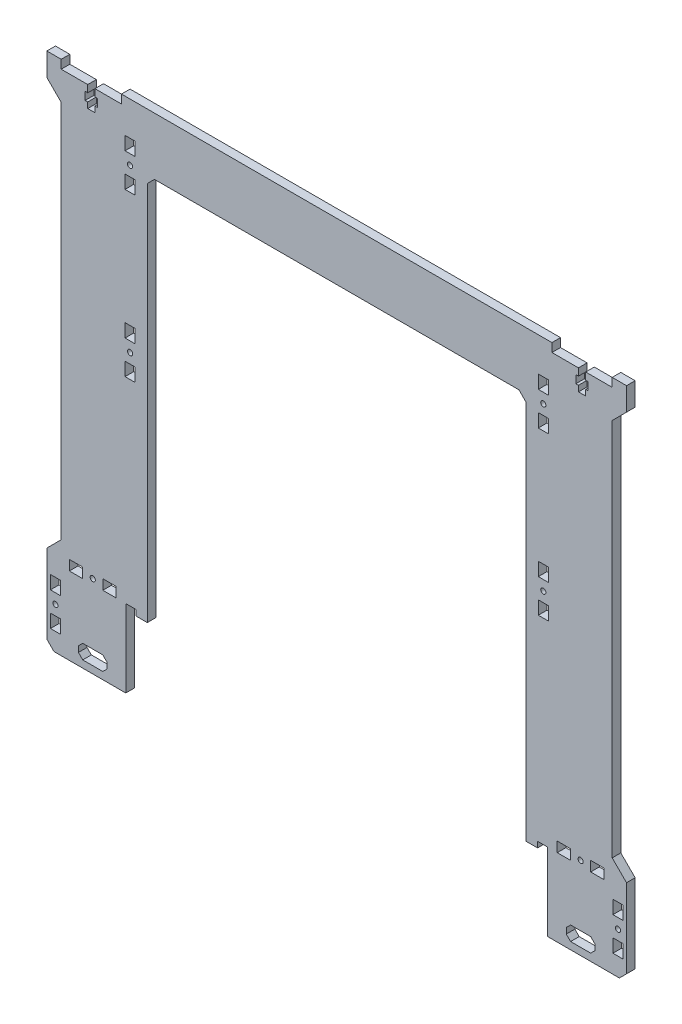
from build123d import *

# Parameters (mm, degrees)
BOSS_EXTRU_1_DEPTH      = 3
ENL_V_MAT_EXTRU_1_REACH = 8
ESQUISSE2_W             = 7
ESQUISSE2_H             = 9.3
ESQUISSE2_R             = 1.8
ESQUISSE2_W_2           = 9.3
ESQUISSE2_H_2           = 7
CHANFREIN1_SIZE         = 5


with BuildPart() as part:
    # Esquisse1 → Boss.-Extru.1 (new body, symmetric)
    with BuildSketch(Plane.XY):
        Polygon((0, 0), (0, 40), (-150, 40), (-150, 34), (-192, 34), (-192, 40), (-202, 40), (-202, 24), (-192, 14), (-192, -250), (-202, -260), (-202, -320), (-147, -320), (-147, -266), (-140, -266), (-140, -270), (-132, -270), (-132, 0), align=None)
    extrude(amount=BOSS_EXTRU_1_DEPTH, both=True)

    # Esquisse2 → Enlèv. mat.-Extru.1 (cut, up to next)
    with BuildSketch(Plane.XY.offset(3), mode=Mode.PRIVATE) as enl_v_mat_extru_1_sk1:
        with Locations((-144, 11.65)):
            Rectangle(ESQUISSE2_W, ESQUISSE2_H)
    enl_v_mat_extru_1_tool1 = extrude(enl_v_mat_extru_1_sk1.sketch, amount=-ENL_V_MAT_EXTRU_1_REACH, mode=Mode.PRIVATE) & part.part
    add(enl_v_mat_extru_1_tool1.solids().sort_by_distance((-144, 11.65, 3))[0], mode=Mode.SUBTRACT)
    # Esquisse2 → Enlèv. mat.-Extru.1 (cut, up to next)
    with BuildSketch(Plane.XY.offset(3), mode=Mode.PRIVATE) as enl_v_mat_extru_1_sk2:
        with Locations((-144, -11.65)):
            Rectangle(ESQUISSE2_W, ESQUISSE2_H)
    enl_v_mat_extru_1_tool2 = extrude(enl_v_mat_extru_1_sk2.sketch, amount=-ENL_V_MAT_EXTRU_1_REACH, mode=Mode.PRIVATE) & part.part
    add(enl_v_mat_extru_1_tool2.solids().sort_by_distance((-144, -11.65, 3))[0], mode=Mode.SUBTRACT)
    # Esquisse2 → Enlèv. mat.-Extru.1 (cut, up to next)
    with BuildSketch(Plane.XY.offset(3), mode=Mode.PRIVATE) as enl_v_mat_extru_1_sk3:
        with Locations((-144, -101.35)):
            Rectangle(ESQUISSE2_W, ESQUISSE2_H)
    enl_v_mat_extru_1_tool3 = extrude(enl_v_mat_extru_1_sk3.sketch, amount=-ENL_V_MAT_EXTRU_1_REACH, mode=Mode.PRIVATE) & part.part
    add(enl_v_mat_extru_1_tool3.solids().sort_by_distance((-144, -101.35, 3))[0], mode=Mode.SUBTRACT)
    # Esquisse2 → Enlèv. mat.-Extru.1 (cut, up to next)
    with BuildSketch(Plane.XY.offset(3), mode=Mode.PRIVATE) as enl_v_mat_extru_1_sk4:
        with Locations((-144, -113)):
            Circle(ESQUISSE2_R)
    enl_v_mat_extru_1_tool4 = extrude(enl_v_mat_extru_1_sk4.sketch, amount=-ENL_V_MAT_EXTRU_1_REACH, mode=Mode.PRIVATE) & part.part
    add(enl_v_mat_extru_1_tool4.solids().sort_by_distance((-144, -113, 3))[0], mode=Mode.SUBTRACT)
    # Esquisse2 → Enlèv. mat.-Extru.1 (cut, up to next)
    with BuildSketch(Plane.XY.offset(3), mode=Mode.PRIVATE) as enl_v_mat_extru_1_sk5:
        with Locations((-144, 0)):
            Circle(ESQUISSE2_R)
    enl_v_mat_extru_1_tool5 = extrude(enl_v_mat_extru_1_sk5.sketch, amount=-ENL_V_MAT_EXTRU_1_REACH, mode=Mode.PRIVATE) & part.part
    add(enl_v_mat_extru_1_tool5.solids().sort_by_distance((-144, 0, 3))[0], mode=Mode.SUBTRACT)
    # Esquisse2 → Enlèv. mat.-Extru.1 (cut, up to next)
    with BuildSketch(Plane.XY.offset(3), mode=Mode.PRIVATE) as enl_v_mat_extru_1_sk6:
        Polygon((-168.5, 34), (-173.5, 34), (-173.5, 29), (-175.3, 29), (-175.3, 23.5), (-173.5, 23.5), (-173.5, 19.5), (-168.5, 19.5), (-168.5, 23.5), (-166.7, 23.5), (-166.7, 29), (-168.5, 29), align=None)
    enl_v_mat_extru_1_tool6 = extrude(enl_v_mat_extru_1_sk6.sketch, amount=-ENL_V_MAT_EXTRU_1_REACH, mode=Mode.PRIVATE) & part.part
    add(enl_v_mat_extru_1_tool6.solids().sort_by_distance((-171, 26.642741, 3))[0], mode=Mode.SUBTRACT)
    # Esquisse2 → Enlèv. mat.-Extru.1 (cut, up to next)
    with BuildSketch(Plane.XY.offset(3), mode=Mode.PRIVATE) as enl_v_mat_extru_1_sk7:
        with Locations((-144, -124.65)):
            Rectangle(ESQUISSE2_W, ESQUISSE2_H)
    enl_v_mat_extru_1_tool7 = extrude(enl_v_mat_extru_1_sk7.sketch, amount=-ENL_V_MAT_EXTRU_1_REACH, mode=Mode.PRIVATE) & part.part
    add(enl_v_mat_extru_1_tool7.solids().sort_by_distance((-144, -124.65, 3))[0], mode=Mode.SUBTRACT)
    # Esquisse2 → Enlèv. mat.-Extru.1 (cut, up to next)
    with BuildSketch(Plane.XY.offset(3), mode=Mode.PRIVATE) as enl_v_mat_extru_1_sk8:
        with Locations((-158.35, -262.5)):
            Rectangle(ESQUISSE2_W_2, ESQUISSE2_H_2)
    enl_v_mat_extru_1_tool8 = extrude(enl_v_mat_extru_1_sk8.sketch, amount=-ENL_V_MAT_EXTRU_1_REACH, mode=Mode.PRIVATE) & part.part
    add(enl_v_mat_extru_1_tool8.solids().sort_by_distance((-158.35, -262.5, 3))[0], mode=Mode.SUBTRACT)
    # Esquisse2 → Enlèv. mat.-Extru.1 (cut, up to next)
    with BuildSketch(Plane.XY.offset(3), mode=Mode.PRIVATE) as enl_v_mat_extru_1_sk9:
        with Locations((-170, -262.5)):
            Circle(ESQUISSE2_R)
    enl_v_mat_extru_1_tool9 = extrude(enl_v_mat_extru_1_sk9.sketch, amount=-ENL_V_MAT_EXTRU_1_REACH, mode=Mode.PRIVATE) & part.part
    add(enl_v_mat_extru_1_tool9.solids().sort_by_distance((-170, -262.5, 3))[0], mode=Mode.SUBTRACT)
    # Esquisse2 → Enlèv. mat.-Extru.1 (cut, up to next)
    with BuildSketch(Plane.XY.offset(3), mode=Mode.PRIVATE) as enl_v_mat_extru_1_sk10:
        with Locations((-181.65, -262.5)):
            Rectangle(ESQUISSE2_W_2, ESQUISSE2_H_2)
    enl_v_mat_extru_1_tool10 = extrude(enl_v_mat_extru_1_sk10.sketch, amount=-ENL_V_MAT_EXTRU_1_REACH, mode=Mode.PRIVATE) & part.part
    add(enl_v_mat_extru_1_tool10.solids().sort_by_distance((-181.65, -262.5, 3))[0], mode=Mode.SUBTRACT)
    # Esquisse2 → Enlèv. mat.-Extru.1 (cut, up to next)
    with BuildSketch(Plane.XY.offset(3), mode=Mode.PRIVATE) as enl_v_mat_extru_1_sk11:
        with Locations((-196, -279.35)):
            Rectangle(ESQUISSE2_W, ESQUISSE2_H)
    enl_v_mat_extru_1_tool11 = extrude(enl_v_mat_extru_1_sk11.sketch, amount=-ENL_V_MAT_EXTRU_1_REACH, mode=Mode.PRIVATE) & part.part
    add(enl_v_mat_extru_1_tool11.solids().sort_by_distance((-196, -279.35, 3))[0], mode=Mode.SUBTRACT)
    # Esquisse2 → Enlèv. mat.-Extru.1 (cut, up to next)
    with BuildSketch(Plane.XY.offset(3), mode=Mode.PRIVATE) as enl_v_mat_extru_1_sk12:
        with Locations((-196, -291)):
            Circle(ESQUISSE2_R)
    enl_v_mat_extru_1_tool12 = extrude(enl_v_mat_extru_1_sk12.sketch, amount=-ENL_V_MAT_EXTRU_1_REACH, mode=Mode.PRIVATE) & part.part
    add(enl_v_mat_extru_1_tool12.solids().sort_by_distance((-196, -291, 3))[0], mode=Mode.SUBTRACT)
    # Esquisse2 → Enlèv. mat.-Extru.1 (cut, up to next)
    with BuildSketch(Plane.XY.offset(3), mode=Mode.PRIVATE) as enl_v_mat_extru_1_sk13:
        with Locations((-196, -302.65)):
            Rectangle(ESQUISSE2_W, ESQUISSE2_H)
    enl_v_mat_extru_1_tool13 = extrude(enl_v_mat_extru_1_sk13.sketch, amount=-ENL_V_MAT_EXTRU_1_REACH, mode=Mode.PRIVATE) & part.part
    add(enl_v_mat_extru_1_tool13.solids().sort_by_distance((-196, -302.65, 3))[0], mode=Mode.SUBTRACT)
    # Esquisse2 → Enlèv. mat.-Extru.1 (cut, up to next)
    with BuildSketch(Plane.XY.offset(3), mode=Mode.PRIVATE) as enl_v_mat_extru_1_sk14:
        Polygon((-180, -312), (-180, -308), (-177, -305), (-163, -305), (-160, -308), (-160, -312), (-163, -315), (-177, -315), align=None)
    enl_v_mat_extru_1_tool14 = extrude(enl_v_mat_extru_1_sk14.sketch, amount=-ENL_V_MAT_EXTRU_1_REACH, mode=Mode.PRIVATE) & part.part
    add(enl_v_mat_extru_1_tool14.solids().sort_by_distance((-170, -310, 3))[0], mode=Mode.SUBTRACT)

    # Chanfrein1
    chanfrein1_edges = [part.edges().sort_by_distance(p)[0] for p in [
        (-132, 0, 0),
        (-202, -320, 0),
    ]]
    chamfer(chanfrein1_edges, length=CHANFREIN1_SIZE)

    # Symétrie1: part across plane


with BuildPart() as part_1:
    add(part.part)
    add(part.part.mirror(Plane(origin=(0, 0, 3), x_dir=(0, 0, 1), z_dir=(-1, 0, 0))))


solid = part_1.part
